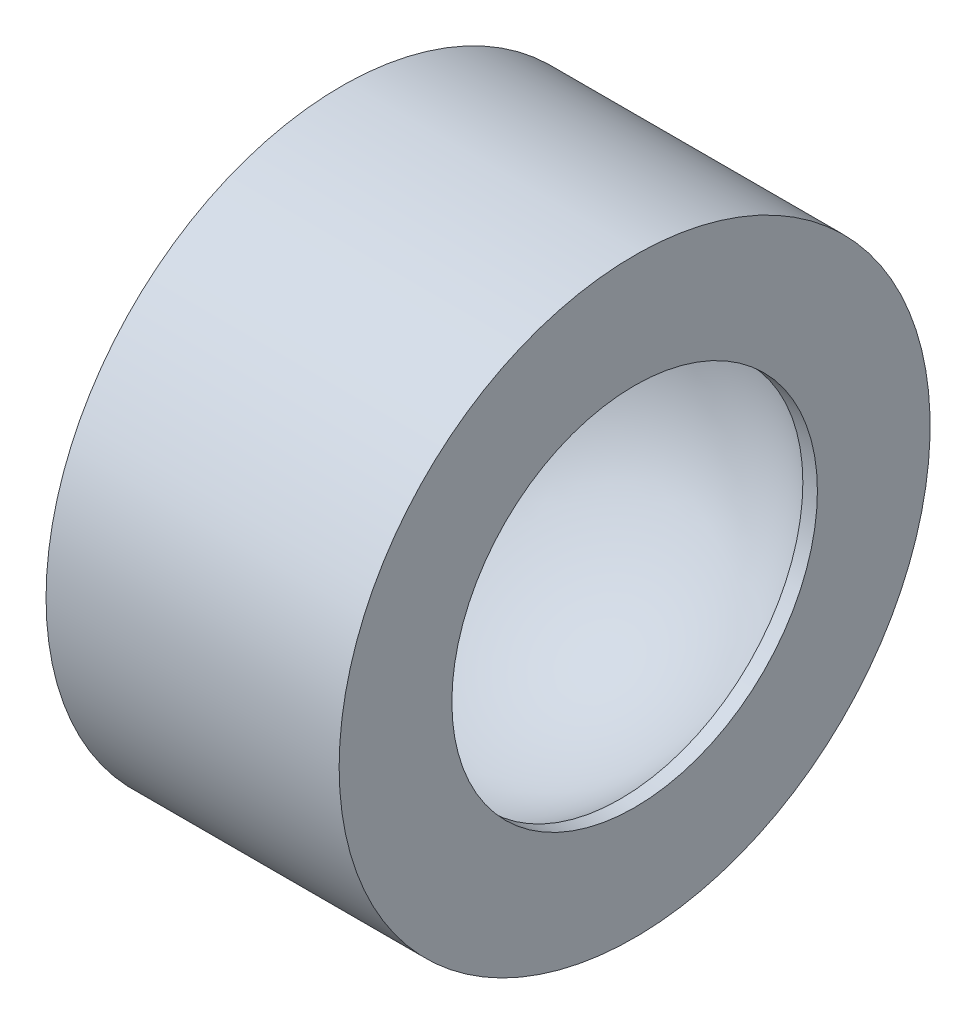
from build123d import *


with BuildPart() as part:
    # Sketch1 → Revolve1 (revolve)
    with BuildSketch(Plane.XY):
        with BuildLine():
            Line((6.5, 5), (-6.5, 5))
            Line((-6.5, 5), (-6.5, 0))
            Line((-6.5, 0), (-5.854496714, 0))
            ThreePointArc((-5.854496714, 0), (0, 1.89291247), (5.854496714, 0))
            Line((5.854496714, 0), (6.5, 0))
            Line((6.5, 0), (6.5, 5))
        make_face()
    revolve(axis=Axis((-17.079956838, -8.10708753, 0), (1, 0, 0)))


solid = part.part
